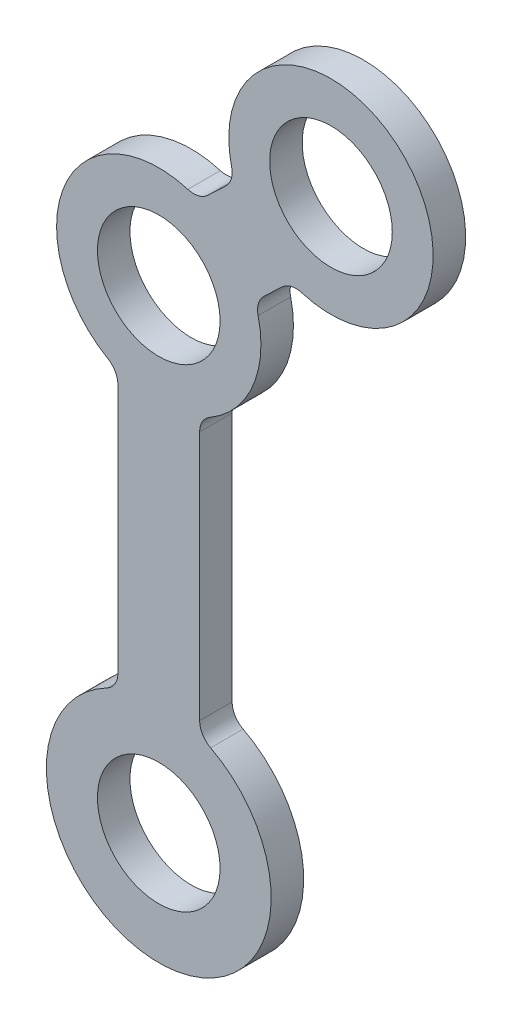
from build123d import *

# Parameters (mm, degrees)
SKETCH1_R           = 3
BOSS_EXTRUDE1_DEPTH = 1.59


with BuildPart() as part:
    # Sketch1 → Boss-Extrude1 (new body)
    with BuildSketch(Plane.XY):
        with BuildLine():
            Line((5.147045903, 25.318285926), (6.030288505, 26.155519293))
            ThreePointArc((6.030288505, 26.155519293), (6.485334938, 26.402261945), (7.002788035, 26.388424134))
            ThreePointArc((7.002788035, 26.388424134), (12.054313697, 34.621489097), (3.563031664, 30.017208519))
            ThreePointArc((3.563031664, 30.017208519), (3.549193853, 29.499755422), (3.278483409, 29.058546801))
            Line((3.278483409, 29.058546801), (2.395240806, 28.221313434))
            ThreePointArc((2.395240806, 28.221313434), (1.940194374, 27.974570781), (1.422741277, 27.988408592))
            ThreePointArc((1.422741277, 27.988408592), (-4.593407333, 25.170095968), (-2.5, 18.864972981))
            ThreePointArc((-2.5, 18.864972981), (-2.133974596, 18.498947577), (-2, 17.998947577))
            Line((-2, 17.998947577), (-2, 5.766281297))
            ThreePointArc((-2, 5.766281297), (-2.145149586, 5.247406776), (-2.538461538, 4.879161098))
            ThreePointArc((-2.538461538, 4.879161098), (0, -5.5), (2.538461538, 4.879161098))
            ThreePointArc((2.538461538, 4.879161098), (2.145149586, 5.247406776), (2, 5.766281297))
            Line((2, 5.766281297), (2, 17.998947577))
            ThreePointArc((2, 17.998947577), (2.133974596, 18.498947577), (2.5, 18.864972981))
            ThreePointArc((2.5, 18.864972981), (4.593407333, 21.220104032), (4.862497647, 24.359624207))
            ThreePointArc((4.862497647, 24.359624207), (4.876335458, 24.877077304), (5.147045903, 25.318285926))
        make_face()
        Circle(SKETCH1_R, mode=Mode.SUBTRACT)
        with Locations((0, 23.1951)):
            Circle(SKETCH1_R, mode=Mode.SUBTRACT)
        with Locations((8.425529312, 31.181732726)):
            Circle(SKETCH1_R, mode=Mode.SUBTRACT)
    extrude(amount=BOSS_EXTRUDE1_DEPTH)


solid = part.part
